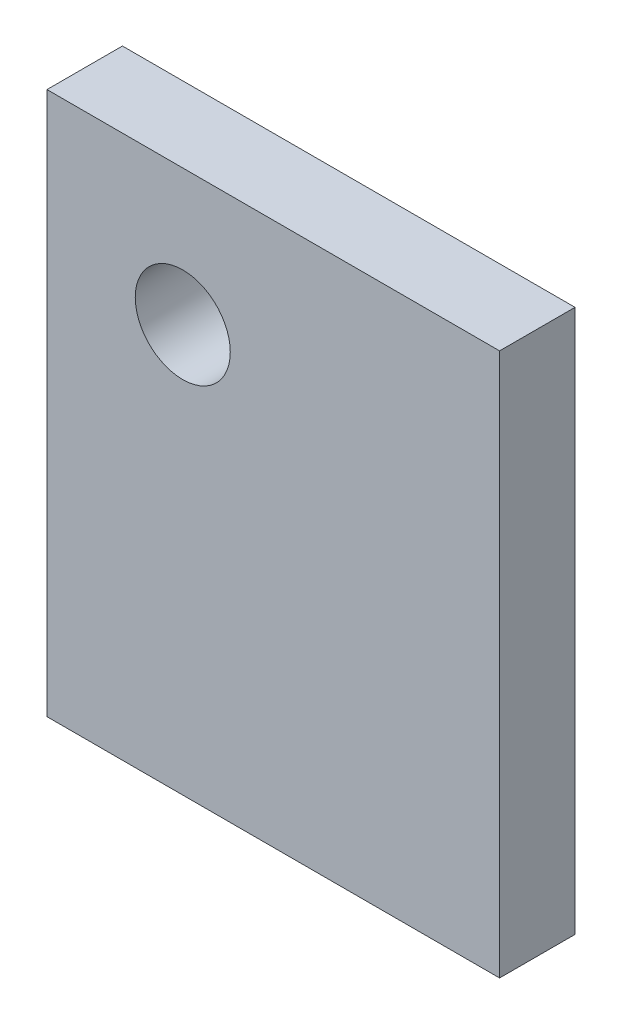
from build123d import *

# Parameters (mm, degrees)
SKETCH1_W               = 38.1
SKETCH1_H               = 45.72
BOSS_EXTRUDE1_DEPTH     = 6.35
SKETCH2_R               = 4
CUT_EXTRUDE1_DEPTH      = 1
CUT_EXTRUDE1_DEPTH_BACK = 7.35


with BuildPart() as part:
    # Sketch1 → Boss-Extrude1 (new body)
    with BuildSketch(Plane.XY):
        with Locations((19.05, 22.86)):
            Rectangle(SKETCH1_W, SKETCH1_H)
    extrude(amount=BOSS_EXTRUDE1_DEPTH)

    # Sketch2 → Cut-Extrude1 (cut, two sides)
    with BuildSketch(Plane.XY.offset(6.35)) as cut_extrude1_sk:
        with Locations((11.43, 34.29)):
            Circle(SKETCH2_R)
    extrude(amount=CUT_EXTRUDE1_DEPTH, mode=Mode.SUBTRACT)
    extrude(cut_extrude1_sk.sketch, amount=-CUT_EXTRUDE1_DEPTH_BACK, mode=Mode.SUBTRACT)


solid = part.part
